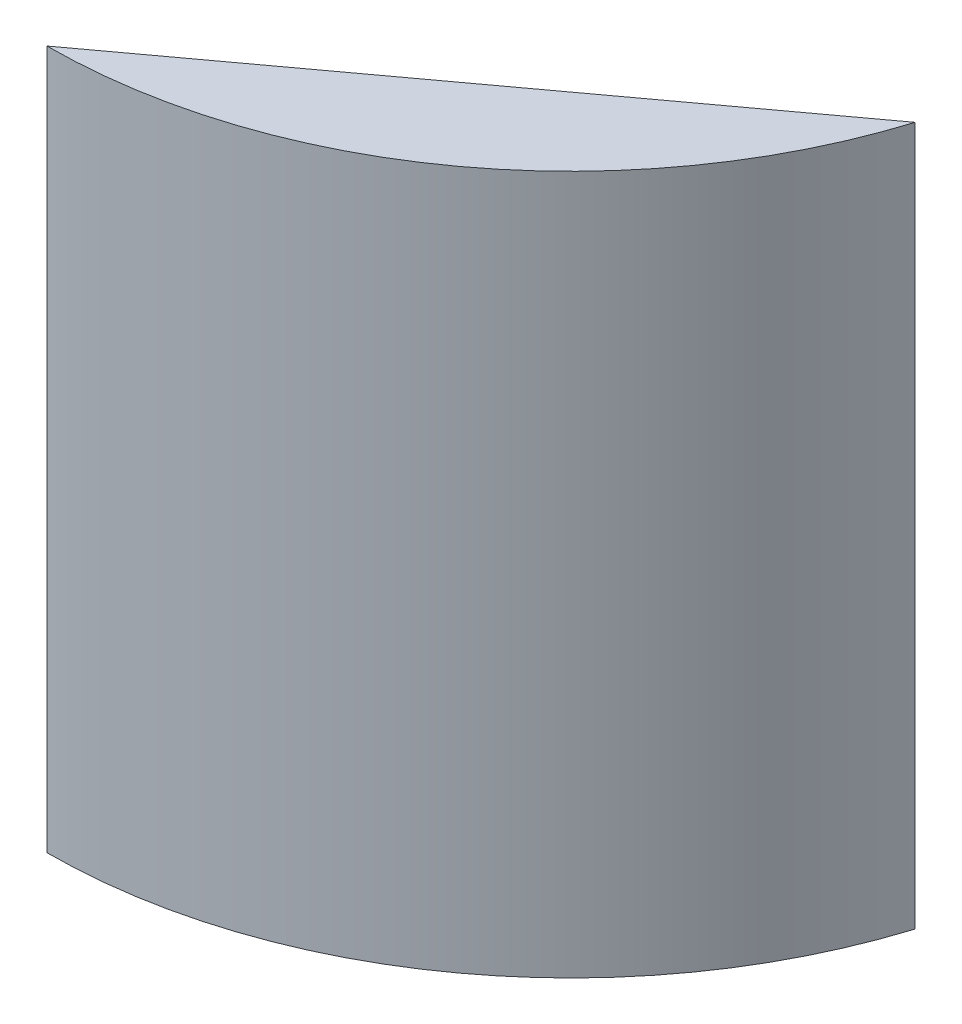
from build123d import *

# Parameters (mm, degrees)
SKETCH1_R           = 85.725
BOSS_EXTRUDE1_DEPTH = 114.3
CUT_EXTRUDE1_DEPTH  = 152.4
SKETCH3_R           = 2.778125
CUT_EXTRUDE2_DEPTH  = 7.9375
SKETCH4_R           = 5.588
CUT_EXTRUDE3_DEPTH  = 6.096


with BuildPart() as part:
    # Sketch1 → Boss-Extrude1 (new body)
    with BuildSketch(Plane(origin=(0, 0, 0), x_dir=(1, 0, 0), z_dir=(0, 1, 0))):
        Circle(SKETCH1_R)
    extrude(amount=BOSS_EXTRUDE1_DEPTH)

    # Sketch2 → Cut-Extrude1 (cut)
    with BuildSketch(Plane(origin=(0, 114.3, 0), x_dir=(1, 0, 0), z_dir=(0, 1, 0))):
        Polygon((0, -85.725), (81.83903771, -25.517592593), (151.304734273, 75.062868172), (-38.51393236, 115.934796391), (-149.339737724, 18.86396687), (-68.774879215, -104.537816407), align=None)
    extrude(amount=-CUT_EXTRUDE1_DEPTH, mode=Mode.SUBTRACT)

    # Sketch3 → Cut-Extrude2 (cut)
    with BuildSketch(Plane(origin=(40.919518855, 0, 55.621296296), x_dir=(-0.80550234, 0, 0.592592593), z_dir=(-0.592592593, 0, -0.80550234))):
        with Locations((2.54, 104.14)):
            Circle(SKETCH3_R)
        with Locations((27.94, 104.14)):
            Circle(SKETCH3_R)
        with Locations((2.54, 27.94)):
            Circle(SKETCH3_R)
        with Locations((27.94, 27.94)):
            Circle(SKETCH3_R)
    extrude(amount=-CUT_EXTRUDE2_DEPTH, mode=Mode.SUBTRACT)

    # Sketch4 → Cut-Extrude3 (cut)
    with BuildSketch(Plane(origin=(0, 0, 0), x_dir=(-1, 0, 0), z_dir=(0, -1, 0))):
        with Locations((-45.859759427, -62.336492182)):
            Circle(SKETCH4_R)
    extrude(amount=-CUT_EXTRUDE3_DEPTH, mode=Mode.SUBTRACT)


solid = part.part
